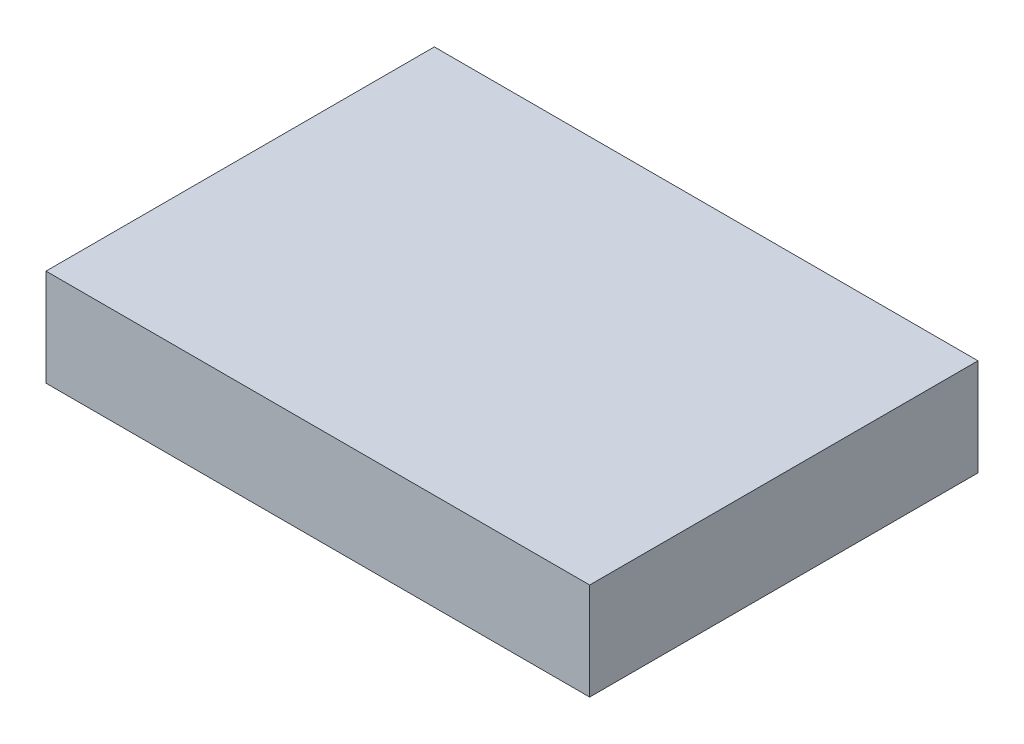
from build123d import *

# Parameters (mm, degrees)
SKETCH1_W           = 177.8
SKETCH1_H           = 127
BOSS_EXTRUDE1_DEPTH = 31.75


with BuildPart() as part:
    # Sketch1 → Boss-Extrude1 (new body)
    with BuildSketch(Plane(origin=(0, 0, 0), x_dir=(1, 0, 0), z_dir=(0, 1, 0))):
        Rectangle(SKETCH1_W, SKETCH1_H)
    extrude(amount=BOSS_EXTRUDE1_DEPTH)


solid = part.part
